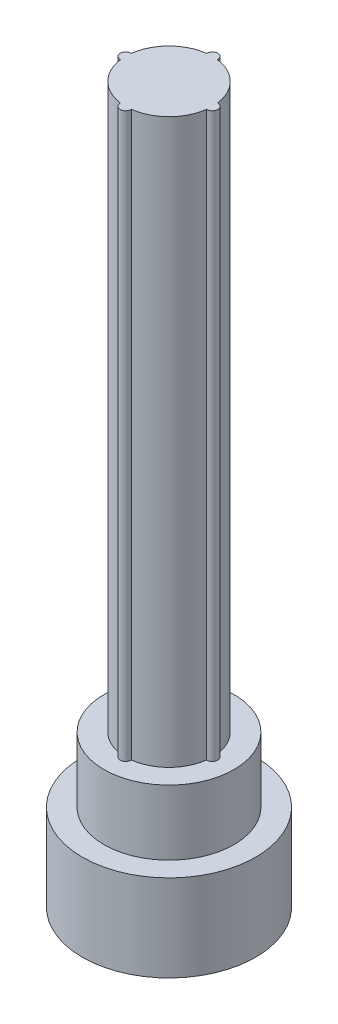
from build123d import *

# Parameters (mm, degrees)
SKETCH1_R           = 2
BOSS_EXTRUDE1_DEPTH = 2
SKETCH2_R           = 1.5
BOSS_EXTRUDE2_DEPTH = 1.5
SKETCH3_R           = 1
BOSS_EXTRUDE3_DEPTH = 13
SKETCH4_R           = 0.125
BOSS_EXTRUDE4_DEPTH = 13


with BuildPart() as part:
    # Sketch1 → Boss-Extrude1 (new body)
    with BuildSketch(Plane(origin=(0, 0, 0), x_dir=(1, 0, 0), z_dir=(0, 1, 0))):
        Circle(SKETCH1_R)
    extrude(amount=BOSS_EXTRUDE1_DEPTH)

    # Sketch2 → Boss-Extrude2 (add)
    with BuildSketch(Plane(origin=(0, 2, 0), x_dir=(1, 0, 0), z_dir=(0, 1, 0))):
        Circle(SKETCH2_R)
    extrude(amount=BOSS_EXTRUDE2_DEPTH)

    # Sketch3 → Boss-Extrude3 (add)
    with BuildSketch(Plane(origin=(0, 3.5, 0), x_dir=(1, 0, 0), z_dir=(0, 1, 0))):
        Circle(SKETCH3_R)
    extrude(amount=BOSS_EXTRUDE3_DEPTH)

    # Sketch4 → Boss-Extrude4 (add)
    with BuildSketch(Plane(origin=(0, 16.5, 0), x_dir=(1, 0, 0), z_dir=(0, 1, 0))):
        with Locations((0, 1)):
            Circle(SKETCH4_R)
        with Locations((-1, 0)):
            Circle(SKETCH4_R)
        with Locations((0, -1)):
            Circle(SKETCH4_R)
        with Locations((1, 0)):
            Circle(SKETCH4_R)
    extrude(amount=-BOSS_EXTRUDE4_DEPTH)


solid = part.part
